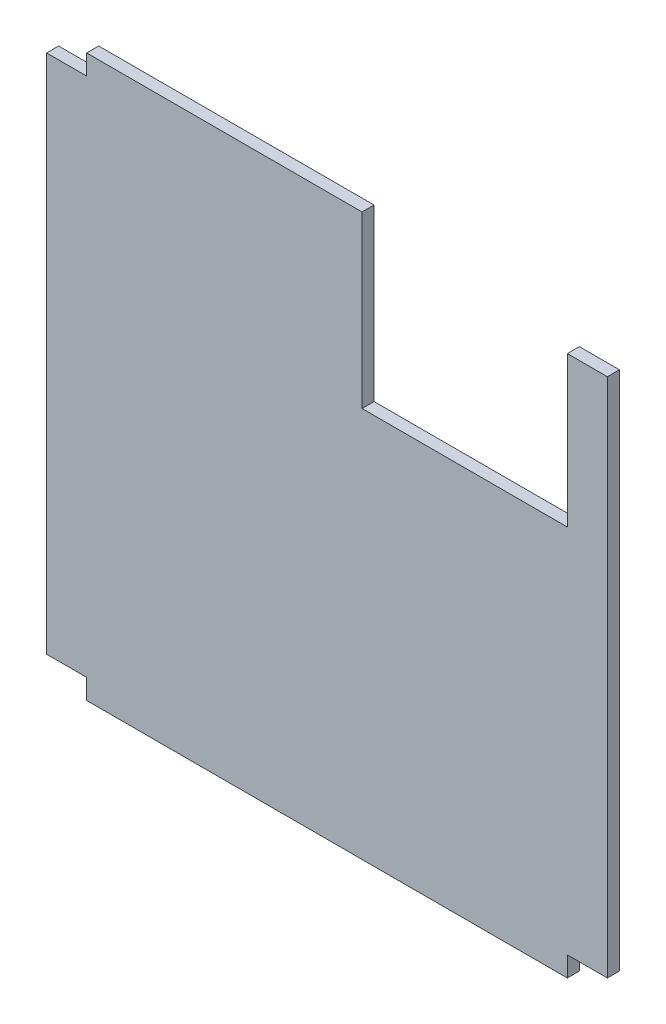
from build123d import *

# Parameters (mm, degrees)
EXTRUDE_1_DEPTH     = 12
SKETCH_3_W          = 205
SKETCH_3_H          = 170
CUT_EXTRUDE_2_DEPTH = 12
SKETCH_4_W          = 12
SKETCH_4_H          = 150
EXTRUDE_2_DEPTH     = 2
SKETCH_5_W          = 2
SKETCH_5_H          = 12
CUT_EXTRUDE_3_DEPTH = 150


with BuildPart() as part:
    # ｽｹｯﾁ1 → ﾎﾞｽ - 押し出し1 (new body)
    with BuildSketch(Plane.XY):
        Polygon((0, 0), (480, 0), (480, -20), (520, -20), (520, -540), (480, -540), (480, -560), (0, -560), (0, -540), (-40, -540), (-40, -20), (0, -20), align=None)
    extrude(amount=EXTRUDE_1_DEPTH)

    # ｽｹｯﾁ3 → ｶｯﾄ - 押し出し2 (cut)
    with BuildSketch(Plane.XY.offset(12)):
        with Locations((377.5, -85)):
            Rectangle(SKETCH_3_W, SKETCH_3_H)
    extrude(amount=-CUT_EXTRUDE_2_DEPTH, mode=Mode.SUBTRACT)

    # ｽｹｯﾁ4 → ﾎﾞｽ - 押し出し2 (add)
    with BuildSketch(Plane.ZY.offset(-480)):
        with Locations((6, -95)):
            Rectangle(SKETCH_4_W, SKETCH_4_H)
    extrude(amount=EXTRUDE_2_DEPTH)

    # ｽｹｯﾁ5 → ｶｯﾄ - 押し出し3 (cut)
    with BuildSketch(Plane(origin=(0, -20, 0), x_dir=(1, 0, 0), z_dir=(0, 1, 0))):
        with Locations((479, -6)):
            Rectangle(SKETCH_5_W, SKETCH_5_H)
    extrude(amount=-CUT_EXTRUDE_3_DEPTH, mode=Mode.SUBTRACT)


solid = part.part
